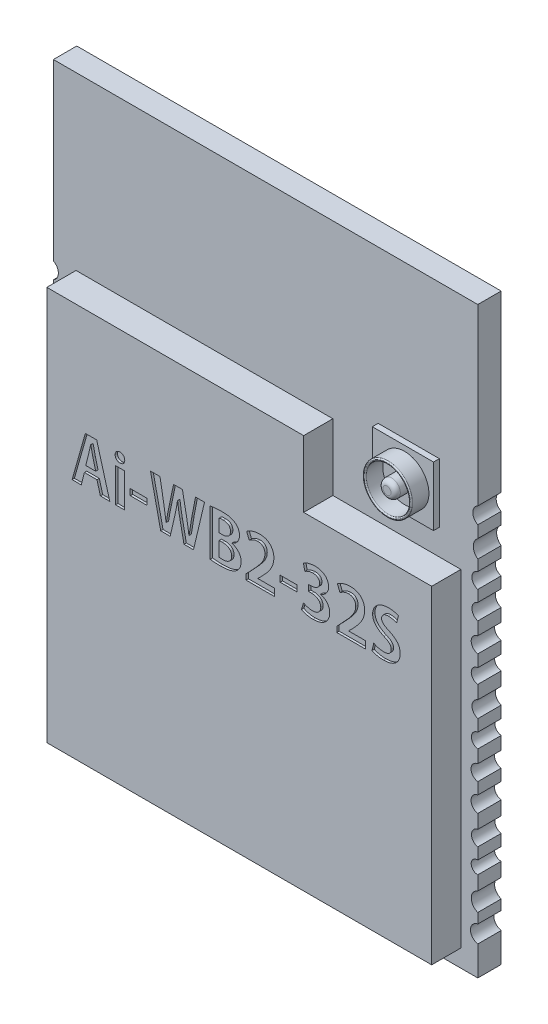
from build123d import *

# Parameters (mm, degrees)
BOSS_EXTRU_1_DEPTH      = 1
BOSS_EXTRU_2_DEPTH      = 1.25
COAXCADRE_W             = 2.617926319
COAXCADRE_H             = 2.543658905
BOSS_EXTRU_3_DEPTH      = 0.25
COAD_REFLIEF_R          = 1.042475493
COAD_REFLIEF_R_2        = 0.933619224
COAD_REFLIEF_R_3        = 0.369372033
BOSS_EXTRU_5_DEPTH      = 1
CONG_1_R                = 0.05
CONG_2_R                = 0.2
ESQUISSE7_W             = 0.383107528
ESQUISSE7_H             = 1.451751746
ESQUISSE7_W_2           = 0.716440922
ESQUISSE7_H_2           = 0.262443856
ENL_V_MAT_EXTRU_1_DEPTH = 0.1


with BuildPart() as part:
    # fond pcb → Boss.-Extru.1 (new body)
    with BuildSketch(Plane.XY):
        with BuildLine():
            Line((-9.810904604, 5.528505039), (-9.810904604, 5.018441254))
            ThreePointArc((-9.810904604, 5.018441254), (-9.618337887, 4.638599071), (-9.810904604, 4.258756888))
            Line((-9.810904604, 4.258756888), (-9.810904604, 3.797103699))
            ThreePointArc((-9.810904604, 3.797103699), (-9.557628015, 3.466729738), (-9.810904604, 3.136355778))
            Line((-9.810904604, 3.136355778), (-9.810904604, 2.653255527))
            ThreePointArc((-9.810904604, 2.653255527), (-9.560806021, 2.310466155), (-9.810904604, 1.967676782))
            Line((-9.810904604, 1.967676782), (-9.810904604, 1.414727565))
            ThreePointArc((-9.810904604, 1.414727565), (-9.528239409, 1.080368734), (-9.810904604, 0.746009903))
            Line((-9.810904604, 0.746009903), (-9.810904604, 0.232064282))
            ThreePointArc((-9.810904604, 0.232064282), (-9.530829797, -0.076435621), (-9.810904604, -0.384935524))
            Line((-9.810904604, -0.384935524), (-9.810904604, -0.956391193))
            ThreePointArc((-9.810904604, -0.956391193), (-9.563771815, -1.305723123), (-9.810904604, -1.655055053))
            Line((-9.810904604, -1.655055053), (-9.810904604, -2.155701883))
            ThreePointArc((-9.810904604, -2.155701883), (-9.536682912, -2.467131159), (-9.810904604, -2.778560434))
            Line((-9.810904604, -2.778560434), (-9.810904604, -3.327592238))
            ThreePointArc((-9.810904604, -3.327592238), (-9.522985317, -3.658586754), (-9.810904604, -3.98958127))
            Line((-9.810904604, -3.98958127), (-9.810904604, -4.48532252))
            ThreePointArc((-9.810904604, -4.48532252), (-9.521659552, -4.826224315), (-9.810904604, -5.16712611))
            Line((-9.810904604, -5.16712611), (-9.810904604, -5.758860272))
            ThreePointArc((-9.810904604, -5.758860272), (-9.540059049, -6.083008578), (-9.810904604, -6.407156885))
            Line((-9.810904604, -6.407156885), (-9.810904604, -6.895156212))
            ThreePointArc((-9.810904604, -6.895156212), (-9.528679561, -7.168746736), (-9.810904604, -7.442337261))
            Line((-9.810904604, -7.442337261), (-9.810904604, -8.04316978))
            ThreePointArc((-9.810904604, -8.04316978), (-9.530998458, -8.439992227), (-9.810904604, -8.836814674))
            Line((-9.810904604, -8.836814674), (-9.810904604, -9.267226472))
            ThreePointArc((-9.810904604, -9.267226472), (-9.498258669, -9.63677022), (-9.810904604, -10.006313969))
            Line((-9.810904604, -10.006313969), (-9.810904604, -11.267608596))
            Line((-9.810904604, -11.267608596), (-7.355200704, -11.267608596))
            ThreePointArc((-7.355200704, -11.267608596), (-6.993089856, -10.991870647), (-6.630979007, -11.267608596))
            Line((-6.630979007, -11.267608596), (-5.955813326, -11.267608596))
            ThreePointArc((-5.955813326, -11.267608596), (-5.54916478, -10.996984361), (-5.142516233, -11.267608596))
            Line((-5.142516233, -11.267608596), (-4.512187405, -11.267608596))
            ThreePointArc((-4.512187405, -11.267608596), (-4.118037923, -11.010624916), (-3.72388844, -11.267608596))
            Line((-3.72388844, -11.267608596), (-3.099198695, -11.267608596))
            ThreePointArc((-3.099198695, -11.267608596), (-2.710391479, -11.014580554), (-2.3158242, -11.258529123))
            Line((-2.3158242, -11.258529123), (-2.31298932, -11.269461703))
            Line((-2.31298932, -11.269461703), (-1.718131206, -11.267608596))
            ThreePointArc((-1.718131206, -11.267608596), (-1.323373729, -11.005956445), (-0.928616251, -11.267608596))
            Line((-0.928616251, -11.267608596), (-0.271146304, -11.267608596))
            ThreePointArc((-0.271146304, -11.267608596), (0.118853565, -11.015281805), (0.508853434, -11.267608596))
            Line((0.508853434, -11.267608596), (1.176730958, -11.267608596))
            ThreePointArc((1.176730958, -11.267608596), (1.536226215, -11.0110728), (1.895721472, -11.267608596))
            Line((1.895721472, -11.267608596), (2.565065894, -11.267608596))
            ThreePointArc((2.565065894, -11.267608596), (2.962688938, -11.005264515), (3.360311981, -11.267608596))
            Line((3.360311981, -11.267608596), (4.018275915, -11.267608596))
            ThreePointArc((4.018275915, -11.267608596), (4.37585402, -11.012835576), (4.733432125, -11.267608596))
            Line((4.733432125, -11.267608596), (5.473522243, -11.263142705))
            ThreePointArc((5.473522243, -11.263142705), (5.785246092, -11.007420546), (6.093252196, -11.267608596))
            Line((6.093252196, -11.267608596), (8.350588499, -11.267608596))
            Line((8.350588499, -11.267608596), (8.350588499, -10.006313969))
            ThreePointArc((8.350588499, -10.006313969), (8.037942564, -9.63677022), (8.350588499, -9.267226472))
            Line((8.350588499, -9.267226472), (8.350588499, -8.836814674))
            ThreePointArc((8.350588499, -8.836814674), (8.070682352, -8.439992227), (8.350588499, -8.04316978))
            Line((8.350588499, -8.04316978), (8.350588499, -7.442337261))
            ThreePointArc((8.350588499, -7.442337261), (8.068363456, -7.168746736), (8.350588499, -6.895156212))
            Line((8.350588499, -6.895156212), (8.350588499, -6.407156885))
            ThreePointArc((8.350588499, -6.407156885), (8.079742943, -6.083008578), (8.350588499, -5.758860272))
            Line((8.350588499, -5.758860272), (8.350588499, -5.16712611))
            ThreePointArc((8.350588499, -5.16712611), (8.061343447, -4.826224315), (8.350588499, -4.48532252))
            Line((8.350588499, -4.48532252), (8.350588499, -3.98958127))
            ThreePointArc((8.350588499, -3.98958127), (8.062669211, -3.658586754), (8.350588499, -3.327592238))
            Line((8.350588499, -3.327592238), (8.350588499, -2.778560434))
            ThreePointArc((8.350588499, -2.778560434), (8.076366807, -2.467131159), (8.350588499, -2.155701883))
            Line((8.350588499, -2.155701883), (8.350588499, -1.655055053))
            ThreePointArc((8.350588499, -1.655055053), (8.10345571, -1.305723123), (8.350588499, -0.956391193))
            Line((8.350588499, -0.956391193), (8.350588499, -0.384935524))
            ThreePointArc((8.350588499, -0.384935524), (8.070513692, -0.076435621), (8.350588499, 0.232064282))
            Line((8.350588499, 0.232064282), (8.350588499, 0.746009903))
            ThreePointArc((8.350588499, 0.746009903), (8.067923304, 1.080368734), (8.350588499, 1.414727565))
            Line((8.350588499, 1.414727565), (8.350588499, 1.967676782))
            ThreePointArc((8.350588499, 1.967676782), (8.100489916, 2.310466155), (8.350588499, 2.653255527))
            Line((8.350588499, 2.653255527), (8.350588499, 3.136355778))
            ThreePointArc((8.350588499, 3.136355778), (8.09731191, 3.466729738), (8.350588499, 3.797103699))
            Line((8.350588499, 3.797103699), (8.350588499, 4.258756888))
            ThreePointArc((8.350588499, 4.258756888), (8.158021781, 4.638599071), (8.350588499, 5.018441254))
            Line((8.350588499, 5.018441254), (8.350588499, 5.528505039))
            ThreePointArc((8.350588499, 5.528505039), (8.13837513, 5.879127896), (8.350588499, 6.229750754))
            Line((8.350588499, 6.229750754), (8.350588499, 13.692890171))
            Line((8.350588499, 13.692890171), (-9.810904604, 13.692890171))
            Line((-9.810904604, 13.692890171), (-9.810904604, 6.229750754))
            ThreePointArc((-9.810904604, 6.229750754), (-9.598691236, 5.879127896), (-9.810904604, 5.528505039))
        make_face()
    extrude(amount=-BOSS_EXTRU_1_DEPTH)

    # shield alu → Boss.-Extru.2 (add)
    with BuildSketch(Plane.XY):
        Polygon((-8.84180437, 6.358286248), (2.148090098, 6.358286248), (2.148090098, 3.513413278), (7.627000757, 3.513413278), (7.627000757, -10.517900776), (-8.84180437, -10.517900776), align=None)
    extrude(amount=BOSS_EXTRU_2_DEPTH)

    # coaxcadre → Boss.-Extru.3 (add)
    with BuildSketch(Plane.XY):
        with Locations((5.395145389, 5.88540961)):
            Rectangle(COAXCADRE_W, COAXCADRE_H)
    extrude(amount=BOSS_EXTRU_3_DEPTH)

    # coad reflief → Boss.-Extru.5 (add)
    with BuildSketch(Plane.XY):
        with Locations((5.466318326, 5.891598561)):
            Circle(COAD_REFLIEF_R)
        with Locations((5.466318326, 5.891598561)):
            Circle(COAD_REFLIEF_R_2, mode=Mode.SUBTRACT)
        with Locations((5.466318326, 5.854464855)):
            Circle(COAD_REFLIEF_R_3)
    extrude(amount=BOSS_EXTRU_5_DEPTH)

    # Congé1
    cong_1_edges = [part.edges().sort_by_distance(p)[0] for p in [
        (4.532699103, 5.891598561, 1),
        (4.423842833, 5.891598561, 1),
    ]]
    fillet(cong_1_edges, radius=CONG_1_R)

    # Congé2
    cong_2_edges = [part.edges().sort_by_distance(p)[0] for p in [
        (5.096946294, 5.854464855, 1),
    ]]
    fillet(cong_2_edges, radius=CONG_2_R)

    # Esquisse7 → Enlèv. mat.-Extru.1 (cut)
    with BuildSketch(Plane.XY.offset(1.25)):
        Polygon((-7.19342477, 1.770074266), (-7.761614861, -0.228100386), (-7.370658377, -0.228100386), (-7.232520419, 0.300994056), (-6.695606847, 0.300994056), (-6.552256136, -0.228100386), (-6.148267768, -0.228100386), (-6.70863873, 1.770074266), align=None)
        with BuildLine():
            add(Edge.make_bspline(
                [(-7.057893189, 1.049727829), (-7.050373964, 1.081676066), (-7.034602693, 1.148686205), (-7.012461293, 1.251786298), (-6.990337461, 1.356210723), (-6.976379811, 1.425543445), (-6.969646832, 1.458988604)],
                knots=[0, 0, 0, 0, 9.8461e-05, 0.000206518, 0.00031634, 0.000418688, 0.000418688, 0.000418688, 0.000418688], degree=3))
            Line((-6.969646832, 1.458988604), (-6.961457256, 1.459364942))
            add(Edge.make_bspline(
                [(-6.961457256, 1.459364942), (-6.954502063, 1.426435492), (-6.9400326, 1.357929632), (-6.918166943, 1.25374074), (-6.895002191, 1.149107394), (-6.878489745, 1.080258577), (-6.870476376, 1.046846749)],
                knots=[0, 0, 0, 0, 0.000100968, 0.000210052, 0.000319376, 0.000422452, 0.000422452, 0.000422452, 0.000422452], degree=3))
            Line((-6.870476376, 1.046846749), (-6.750340755, 0.587570646))
            Line((-6.750340755, 0.587570646), (-7.177786511, 0.587570646))
            Line((-7.177786511, 0.587570646), (-7.057893189, 1.049727829))
        make_face(mode=Mode.SUBTRACT)
        with BuildLine():
            add(Edge.make_bspline(
                [(-5.507519659, 1.614705059), (-5.508499645, 1.629100853), (-5.510392191, 1.656901967), (-5.520902405, 1.696552351), (-5.538985629, 1.731629997), (-5.563866341, 1.761584282), (-5.594148666, 1.786480237), (-5.630101476, 1.804362004), (-5.670856455, 1.815533443), (-5.699712228, 1.817130857), (-5.71474464, 1.817963029)],
                knots=[0, 0, 0, 0, 4.3222e-05, 8.347e-05, 0.00012209, 0.000160666, 0.000199534, 0.000238826, 0.000280265, 0.000325328, 0.000325328, 0.000325328, 0.000325328], degree=3))
            add(Edge.make_bspline(
                [(-5.71474464, 1.817963029), (-5.729277905, 1.817129964), (-5.757272576, 1.815525274), (-5.796980117, 1.804218639), (-5.832387198, 1.78637651), (-5.862631561, 1.761605013), (-5.887447873, 1.731534068), (-5.905921872, 1.696601634), (-5.917014819, 1.656850163), (-5.918647969, 1.628869221), (-5.919495809, 1.614343082)],
                knots=[0, 0, 0, 0, 4.3561e-05, 8.391e-05, 0.000122866, 0.000161734, 0.00020031, 0.000239104, 0.000279453, 0.000323014, 0.000323014, 0.000323014, 0.000323014], degree=3))
            add(Edge.make_bspline(
                [(-5.919495809, 1.614343082), (-5.918649687, 1.600186032), (-5.917006285, 1.572689164), (-5.905692439, 1.533686776), (-5.888212595, 1.4985451), (-5.863761408, 1.468123639), (-5.833525289, 1.443133558), (-5.798113359, 1.424662732), (-5.757859222, 1.413632315), (-5.729520108, 1.411720118), (-5.71474464, 1.410723135)],
                knots=[0, 0, 0, 0, 4.2435e-05, 8.2421e-05, 0.00012087, 0.000159501, 0.000198608, 0.000237737, 0.000278448, 0.000322797, 0.000322797, 0.000322797, 0.000322797], degree=3))
            add(Edge.make_bspline(
                [(-5.71474464, 1.410723135), (-5.700224915, 1.411452262), (-5.672157858, 1.412861686), (-5.632220948, 1.423564457), (-5.596823214, 1.441443412), (-5.565516908, 1.464989874), (-5.540643604, 1.49531375), (-5.521407964, 1.530280527), (-5.510703702, 1.570889518), (-5.508749622, 1.59945361), (-5.507519659, 1.614705059)],
                knots=[0, 0, 0, 0, 4.3527e-05, 8.4139e-05, 0.000122925, 0.000161917, 0.000200733, 0.000239705, 0.000280781, 0.000325505, 0.000325505, 0.000325505, 0.000325505], degree=3))
        make_face()
        with Locations((-5.712105306, 0.494958111)):
            Rectangle(ESQUISSE7_W, ESQUISSE7_H)
        with Locations((-4.915725069, 0.552879656)):
            Rectangle(ESQUISSE7_W_2, ESQUISSE7_H_2)
        with BuildLine():
            add(Edge.make_bspline(
                [(-2.64360157, 0.914449595), (-2.653942815, 0.854396642), (-2.674400927, 0.73559373), (-2.703544863, 0.558404536), (-2.731194217, 0.382518212), (-2.747359188, 0.265199728), (-2.755468077, 0.206348856)],
                knots=[0, 0, 0, 0, 0.00018281, 0.000361653, 0.000538709, 0.000716926, 0.000716926, 0.000716926, 0.000716926], degree=3))
            Line((-2.755468077, 0.206348856), (-2.76291897, 0.206659648))
            add(Edge.make_bspline(
                [(-2.76291897, 0.206659648), (-2.769900874, 0.26467159), (-2.783780189, 0.379993443), (-2.810605894, 0.552086445), (-2.839544405, 0.724318286), (-2.861114325, 0.839237686), (-2.871983935, 0.89714838)],
                knots=[0, 0, 0, 0, 0.000175279, 0.000348436, 0.000522444, 0.000699205, 0.000699205, 0.000699205, 0.000699205], degree=3))
            Line((-2.871983935, 0.89714838), (-3.040461619, 1.76787921))
            Line((-3.040461619, 1.76787921), (-3.419164672, 1.76787921))
            Line((-3.419164672, 1.76787921), (-3.600734629, 0.907774943))
            add(Edge.make_bspline(
                [(-3.600734629, 0.907774943), (-3.614164951, 0.846478633), (-3.640606658, 0.725798051), (-3.67425059, 0.546549043), (-3.705622498, 0.372638991), (-3.72234603, 0.257932868), (-3.730581379, 0.201446895)],
                knots=[0, 0, 0, 0, 0.000188239, 0.000370607, 0.000547101, 0.000718337, 0.000718337, 0.000718337, 0.000718337], degree=3))
            Line((-3.730581379, 0.201446895), (-3.738209025, 0.201446895))
            add(Edge.make_bspline(
                [(-3.738209025, 0.201446895), (-3.745839855, 0.256770439), (-3.761512784, 0.370399246), (-3.788061293, 0.543795791), (-3.816125562, 0.722256182), (-3.83700353, 0.842248505), (-3.847474311, 0.902427416)],
                knots=[0, 0, 0, 0, 0.00016754, 0.000344109, 0.000526242, 0.000709488, 0.000709488, 0.000709488, 0.000709488], degree=3))
            Line((-3.847474311, 0.902427416), (-4.000188535, 1.76787921))
            Line((-4.000188535, 1.76787921), (-4.407429534, 1.76787921))
            Line((-4.407429534, 1.76787921), (-3.969062257, -0.229925734))
            Line((-3.969062257, -0.229925734), (-3.564420638, -0.229925734))
            Line((-3.564420638, -0.229925734), (-3.369881398, 0.613254392))
            add(Edge.make_bspline(
                [(-3.369881398, 0.613254392), (-3.358156298, 0.665477773), (-3.334783014, 0.769581956), (-3.303784691, 0.927249011), (-3.275720616, 1.087828318), (-3.259046202, 1.196388297), (-3.250566207, 1.251597918)],
                knots=[0, 0, 0, 0, 0.000160564, 0.000320076, 0.000482, 0.000649568, 0.000649568, 0.000649568, 0.000649568], degree=3))
            Line((-3.250566207, 1.251597918), (-3.245376285, 1.25181665))
            add(Edge.make_bspline(
                [(-3.245376285, 1.25181665), (-3.238791014, 1.19628418), (-3.225865186, 1.08728288), (-3.202737067, 0.926236936), (-3.176022283, 0.768773062), (-3.154828594, 0.665066788), (-3.144231346, 0.613211676)],
                knots=[0, 0, 0, 0, 0.00016776, 0.000329285, 0.000488044, 0.000646816, 0.000646816, 0.000646816, 0.000646816], degree=3))
            Line((-3.144231346, 0.613211676), (-2.973021349, -0.229925734))
            Line((-2.973021349, -0.229925734), (-2.565785874, -0.229925734))
            Line((-2.565785874, -0.229925734), (-2.093703986, 1.76787921))
            Line((-2.093703986, 1.76787921), (-2.480188609, 1.76787921))
            Line((-2.480188609, 1.76787921), (-2.64360157, 0.914449595))
        make_face()
        with BuildLine():
            add(Edge.make_bspline(
                [(-1.849359681, -0.228241421), (-1.836926383, -0.23013493), (-1.810481642, -0.234162289), (-1.768346343, -0.238928889), (-1.721699368, -0.243049202), (-1.670517825, -0.246307617), (-1.614968175, -0.249400071), (-1.554752096, -0.2516264), (-1.490137601, -0.253023112), (-1.445513478, -0.253706308), (-1.422511572, -0.254058468)],
                knots=[0, 0, 0, 0, 3.7727e-05, 8.0243e-05, 0.000127184, 0.000178202, 0.00023409, 0.000294088, 0.000358962, 0.000427976, 0.000427976, 0.000427976, 0.000427976], degree=3))
            add(Edge.make_bspline(
                [(-1.422511572, -0.254058468), (-1.400890962, -0.253917225), (-1.358642953, -0.253641226), (-1.296649829, -0.251383895), (-1.237578643, -0.247481333), (-1.181305271, -0.24294806), (-1.128055272, -0.235825288), (-1.07739203, -0.228278797), (-1.02967141, -0.21827668), (-0.970745973, -0.204158776), (-0.903090641, -0.182599101), (-0.829327711, -0.150944025), (-0.764134561, -0.114180089), (-0.727292405, -0.083421829), (-0.709464684, -0.068538072)],
                knots=[0, 0, 0, 0, 6.4861e-05, 0.000126743, 0.000186063, 0.000242461, 0.00029606, 0.000347204, 0.000396086, 0.000442271, 0.000528966, 0.000608681, 0.000682861, 0.000752412, 0.000752412, 0.000752412, 0.000752412], degree=3))
            add(Edge.make_bspline(
                [(-0.709464684, -0.068538072), (-0.695173122, -0.05516164), (-0.666907077, -0.028705551), (-0.630591624, 0.01655376), (-0.599239245, 0.064803371), (-0.573103721, 0.11621769), (-0.55282825, 0.170145552), (-0.538178097, 0.225734967), (-0.528611727, 0.282818118), (-0.527515088, 0.321443934), (-0.526960879, 0.340964266)],
                knots=[0, 0, 0, 0, 5.8661e-05, 0.000116021, 0.000173546, 0.00023105, 0.000288689, 0.000346036, 0.000403317, 0.000461841, 0.000461841, 0.000461841, 0.000461841], degree=3))
            add(Edge.make_bspline(
                [(-0.526960879, 0.340964266), (-0.527621544, 0.356690671), (-0.528915148, 0.387483478), (-0.534527182, 0.432533688), (-0.543707269, 0.475356931), (-0.555679767, 0.516300818), (-0.571117875, 0.555229274), (-0.590139957, 0.592058531), (-0.612394385, 0.626750172), (-0.637753068, 0.659212421), (-0.665734699, 0.689370989), (-0.695842818, 0.717257327), (-0.727991309, 0.742610241), (-0.762047148, 0.765279081), (-0.798048558, 0.785460426), (-0.836281809, 0.802587519), (-0.876220817, 0.817952802), (-0.903963533, 0.82572403), (-0.917986592, 0.829652138)],
                knots=[0, 0, 0, 0, 4.7208e-05, 9.2435e-05, 0.000135995, 0.000178469, 0.000220271, 0.000261421, 0.000302632, 0.00034374, 0.000384833, 0.000425925, 0.000466736, 0.000507523, 0.000548543, 0.000590391, 0.000633112, 0.000676778, 0.000676778, 0.000676778, 0.000676778], degree=3))
            Line((-0.917986592, 0.829652138), (-0.917658125, 0.840220152))
            add(Edge.make_bspline(
                [(-0.917658125, 0.840220152), (-0.904736482, 0.845562119), (-0.879289618, 0.856082166), (-0.843164592, 0.874801451), (-0.809047996, 0.894569537), (-0.777770218, 0.916546359), (-0.74883516, 0.940034389), (-0.722505041, 0.965273732), (-0.698477778, 0.992123055), (-0.670764576, 1.030204857), (-0.641199214, 1.080304654), (-0.616348783, 1.144780695), (-0.600431528, 1.212365046), (-0.598718778, 1.258672923), (-0.597850787, 1.28214091)],
                knots=[0, 0, 0, 0, 4.1928e-05, 8.257e-05, 0.000121954, 0.000160135, 0.000197119, 0.000233657, 0.000269449, 0.000305046, 0.000374829, 0.000443242, 0.000511667, 0.000581974, 0.000581974, 0.000581974, 0.000581974], degree=3))
            add(Edge.make_bspline(
                [(-0.597850787, 1.28214091), (-0.598443978, 1.302804977), (-0.599601837, 1.343139483), (-0.610356669, 1.401649137), (-0.626159728, 1.456670964), (-0.649219941, 1.507536597), (-0.677415391, 1.554514378), (-0.711199543, 1.596763037), (-0.749484078, 1.634820374), (-0.778544209, 1.655811097), (-0.793175106, 1.666379291)],
                knots=[0, 0, 0, 0, 6.1933e-05, 0.000120888, 0.000177918, 0.000233279, 0.000287924, 0.000341867, 0.000395196, 0.00044927, 0.00044927, 0.00044927, 0.00044927], degree=3))
            add(Edge.make_bspline(
                [(-0.793175106, 1.666379291), (-0.81068216, 1.677685148), (-0.846052978, 1.700527223), (-0.903638646, 1.7282565), (-0.965080099, 1.750537278), (-1.030657085, 1.767472447), (-1.100924752, 1.77974292), (-1.176491534, 1.788125271), (-1.257646035, 1.793704009), (-1.313652913, 1.793787292), (-1.342571889, 1.793830295)],
                knots=[0, 0, 0, 0, 6.2474e-05, 0.00012622, 0.000191232, 0.000258271, 0.000329131, 0.000405043, 0.000486285, 0.00057302, 0.00057302, 0.00057302, 0.00057302], degree=3))
            add(Edge.make_bspline(
                [(-1.342571889, 1.793830295), (-1.390847854, 1.793225142), (-1.485343056, 1.792040618), (-1.601289213, 1.784931415), (-1.688390804, 1.77600413), (-1.747294702, 1.769523447), (-1.800490455, 1.761664846), (-1.833916941, 1.755343705), (-1.849736387, 1.752352158)],
                knots=[0, 0, 0, 0, 0.000144828, 0.000283485, 0.000348283, 0.000407497, 0.000461251, 0.000509547, 0.000509547, 0.000509547, 0.000509547], degree=3))
            Line((-1.849736387, 1.752352158), (-1.849359681, -0.228241421))
        make_face()
        with BuildLine():
            add(Edge.make_bspline(
                [(-1.466252153, 1.494249072), (-1.456849694, 1.496217877), (-1.435186319, 1.500754028), (-1.397704641, 1.504467998), (-1.351142322, 1.506446198), (-1.317059452, 1.506968796), (-1.298454234, 1.507254073)],
                knots=[0, 0, 0, 0, 2.8803e-05, 6.6364e-05, 0.000112799, 0.000168617, 0.000168617, 0.000168617, 0.000168617], degree=3))
            add(Edge.make_bspline(
                [(-1.298454234, 1.507254073), (-1.277281581, 1.50703822), (-1.236376661, 1.5066212), (-1.177599238, 1.495161128), (-1.123543973, 1.476888908), (-1.082885398, 1.454384136), (-1.053616718, 1.432502795), (-1.035100431, 1.412492916), (-1.019123299, 1.390066476), (-1.005798944, 1.364842896), (-0.99530456, 1.336693351), (-0.987412808, 1.305736494), (-0.982584455, 1.271975965), (-0.981512105, 1.248596676), (-0.980957946, 1.236514959)],
                knots=[0, 0, 0, 0, 6.3403e-05, 0.000122493, 0.00017878, 0.000233973, 0.000261125, 0.000288067, 0.000315375, 0.000343545, 0.000373379, 0.000405297, 0.000439213, 0.000475483, 0.000475483, 0.000475483, 0.000475483], degree=3))
            add(Edge.make_bspline(
                [(-0.980957946, 1.236514959), (-0.981247947, 1.226068354), (-0.981820267, 1.205451889), (-0.986326134, 1.175322052), (-0.994117491, 1.14690912), (-1.003739588, 1.119812011), (-1.016725778, 1.094396431), (-1.032546398, 1.070601181), (-1.051416609, 1.048621571), (-1.072281792, 1.027773505), (-1.096228325, 1.009396768), (-1.122270576, 0.993022948), (-1.150833399, 0.979515847), (-1.181499747, 0.968183746), (-1.21455591, 0.959141114), (-1.249845907, 0.952399433), (-1.287552158, 0.948264134), (-1.313401309, 0.947378811), (-1.326734782, 0.946922145)],
                knots=[0, 0, 0, 0, 3.1333e-05, 6.1837e-05, 9.1106e-05, 0.000119617, 0.000147947, 0.000176498, 0.000205128, 0.000234726, 0.000264821, 0.000295478, 0.000326847, 0.000359418, 0.000393449, 0.000429538, 0.000467098, 0.000507112, 0.000507112, 0.000507112, 0.000507112], degree=3))
            Line((-1.326734782, 0.946922145), (-1.466252153, 0.947298851))
            Line((-1.466252153, 0.947298851), (-1.466252153, 1.494249072))
        make_face(mode=Mode.SUBTRACT)
        with BuildLine():
            add(Edge.make_bspline(
                [(-1.324143872, 0.665247517), (-1.299312962, 0.664656859), (-1.250695334, 0.663500383), (-1.179989853, 0.650512574), (-1.113941298, 0.628028026), (-1.062943509, 0.601807553), (-1.02593099, 0.575878144), (-1.001368656, 0.553147283), (-0.981186102, 0.526660728), (-0.963327775, 0.497872449), (-0.950013521, 0.465433496), (-0.939647924, 0.430083446), (-0.933506884, 0.391554101), (-0.931723693, 0.36486424), (-0.930807107, 0.351145263)],
                knots=[0, 0, 0, 0, 7.4428e-05, 0.000145726, 0.000214649, 0.000283124, 0.00031692, 0.000349999, 0.000383038, 0.000416536, 0.000451343, 0.000487859, 0.000526851, 0.000568092, 0.000568092, 0.000568092, 0.000568092], degree=3))
            add(Edge.make_bspline(
                [(-0.930807107, 0.351145263), (-0.931424362, 0.337673477), (-0.932624582, 0.311478296), (-0.938733208, 0.273562461), (-0.948088905, 0.238572524), (-0.960451694, 0.206201989), (-0.977021124, 0.1772974), (-0.995717765, 0.150308245), (-1.018652287, 0.126985348), (-1.044479076, 0.106511929), (-1.072753844, 0.089173911), (-1.102388426, 0.073472791), (-1.133576668, 0.060139745), (-1.166831608, 0.050231463), (-1.201256422, 0.041744379), (-1.237476844, 0.036264803), (-1.275126394, 0.032659871), (-1.300833441, 0.032565681), (-1.313914267, 0.032517753)],
                knots=[0, 0, 0, 0, 4.0433e-05, 7.862e-05, 0.000114933, 0.000148964, 0.000182219, 0.000214656, 0.00024719, 0.000279932, 0.000313307, 0.000346534, 0.0003805, 0.000414849, 0.000450518, 0.000486784, 0.000524644, 0.000563867, 0.000563867, 0.000563867, 0.000563867], degree=3))
            add(Edge.make_bspline(
                [(-1.313914267, 0.032517753), (-1.329253101, 0.032500288), (-1.358184661, 0.032467345), (-1.398909398, 0.034575163), (-1.434507414, 0.03698427), (-1.456218985, 0.040892645), (-1.466252153, 0.042698751)],
                knots=[0, 0, 0, 0, 4.6005e-05, 8.6772e-05, 0.000122345, 0.000152907, 0.000152907, 0.000152907, 0.000152907], degree=3))
            Line((-1.466252153, 0.042698751), (-1.466252153, 0.665247517))
            Line((-1.466252153, 0.665247517), (-1.324143872, 0.665247517))
        make_face(mode=Mode.SUBTRACT)
        with BuildLine():
            Line((0.18917588, 0.080783222), (0.18917588, 0.086026171))
            Line((0.18917588, 0.086026171), (0.353377604, 0.248557574))
            add(Edge.make_bspline(
                [(0.353377604, 0.248557574), (0.388866031, 0.284405971), (0.458699005, 0.354947279), (0.555204007, 0.465103788), (0.642337014, 0.576745294), (0.709018736, 0.670679491), (0.755882691, 0.747370653), (0.786224099, 0.805835127), (0.812225528, 0.865276029), (0.833864954, 0.925855147), (0.850881526, 0.987485627), (0.863319712, 1.050246719), (0.871362782, 1.114150615), (0.873281222, 1.15718195), (0.874246015, 1.17882264)],
                knots=[0, 0, 0, 0, 0.000151306, 0.000297735, 0.000439018, 0.000576051, 0.000643047, 0.000708484, 0.000773495, 0.000837541, 0.000901304, 0.000965123, 0.001029338, 0.001094304, 0.001094304, 0.001094304, 0.001094304], degree=3))
            add(Edge.make_bspline(
                [(0.874246015, 1.17882264), (0.873985629, 1.199079604), (0.873472999, 1.238960214), (0.866398387, 1.297477056), (0.855214139, 1.353669969), (0.839111246, 1.407297304), (0.817667363, 1.458167719), (0.792059783, 1.50659463), (0.761600055, 1.552543132), (0.726694658, 1.5958854), (0.686842138, 1.635846815), (0.641045051, 1.67015312), (0.590567597, 1.699902733), (0.534602207, 1.723919658), (0.473682487, 1.74307443), (0.407663564, 1.757249624), (0.336554272, 1.766877832), (0.287299656, 1.768737652), (0.261877878, 1.76969756)],
                knots=[0, 0, 0, 0, 6.0738e-05, 0.000119577, 0.000176519, 0.000232465, 0.000287228, 0.000341881, 0.000396578, 0.000452347, 0.000508607, 0.000565395, 0.000623534, 0.000683989, 0.000747671, 0.000814828, 0.000886342, 0.000962624, 0.000962624, 0.000962624, 0.000962624], degree=3))
            add(Edge.make_bspline(
                [(0.261877878, 1.76969756), (0.23381876, 1.768755735), (0.178652442, 1.766904036), (0.097771796, 1.756630546), (0.020439138, 1.740066535), (-0.052610717, 1.717319949), (-0.121021392, 1.690786746), (-0.183492696, 1.660905573), (-0.240434537, 1.629350615), (-0.274175231, 1.604515096), (-0.290535496, 1.592472792)],
                knots=[0, 0, 0, 0, 8.419e-05, 0.000165523, 0.000244215, 0.000321147, 0.000394811, 0.000464132, 0.000528816, 0.000589702, 0.000589702, 0.000589702, 0.000589702], degree=3))
            Line((-0.290535496, 1.592472792), (-0.183535969, 1.315497595))
            add(Edge.make_bspline(
                [(-0.183535969, 1.315497595), (-0.171659587, 1.324246543), (-0.147176062, 1.342282768), (-0.107755644, 1.367337475), (-0.064853652, 1.39105334), (-0.019502646, 1.413708532), (0.028507682, 1.433037175), (0.078617499, 1.447465227), (0.130575296, 1.456775481), (0.16593738, 1.458495627), (0.183823565, 1.459365678)],
                knots=[0, 0, 0, 0, 4.4244e-05, 9.1211e-05, 0.000139995, 0.00019126, 0.000243216, 0.000295011, 0.000347457, 0.000401134, 0.000401134, 0.000401134, 0.000401134], degree=3))
            add(Edge.make_bspline(
                [(0.183823565, 1.459365678), (0.196786075, 1.458820178), (0.221919785, 1.457762477), (0.258246282, 1.452796187), (0.291857719, 1.445401152), (0.322885077, 1.435175765), (0.351123951, 1.422043109), (0.37667477, 1.406182403), (0.399173891, 1.387333778), (0.425762628, 1.359313811), (0.452256361, 1.318600579), (0.475799414, 1.264786438), (0.48910877, 1.205103324), (0.490446648, 1.163679056), (0.491138856, 1.142246465)],
                knots=[0, 0, 0, 0, 3.8904e-05, 7.5434e-05, 0.00010983, 0.000142026, 0.000173234, 0.000203051, 0.000231971, 0.000261045, 0.000318669, 0.000376599, 0.000436517, 0.000500754, 0.000500754, 0.000500754, 0.000500754], degree=3))
            add(Edge.make_bspline(
                [(0.491138856, 1.142246465), (0.490447703, 1.125752458), (0.489053483, 1.092480106), (0.481118024, 1.042542708), (0.469186503, 0.991968587), (0.451440451, 0.941078316), (0.429587097, 0.889403821), (0.403083871, 0.83719524), (0.371551292, 0.784645849), (0.3350317, 0.731428416), (0.294148731, 0.676883861), (0.249397175, 0.620254959), (0.201242944, 0.560966904), (0.148717086, 0.499576115), (0.092285986, 0.435836054), (0.031268186, 0.370359795), (-0.033022022, 0.302048671), (-0.077672086, 0.256183257), (-0.100490213, 0.232744035)],
                knots=[0, 0, 0, 0, 4.9489e-05, 9.9831e-05, 0.000151413, 0.000205192, 0.000261289, 0.000319637, 0.000380684, 0.000445004, 0.00051318, 0.000585145, 0.000661527, 0.000742304, 0.00082751, 0.000916899, 0.001010791, 0.001108924, 0.001108924, 0.001108924, 0.001108924], degree=3))
            Line((-0.100490213, 0.232744035), (-0.31906755, -5.0538e-05))
            Line((-0.31906755, -5.0538e-05), (-0.31906755, -0.229925734))
            Line((-0.31906755, -0.229925734), (0.911111993, -0.229925734))
            Line((0.911111993, -0.229925734), (0.911111993, 0.080783222))
            Line((0.911111993, 0.080783222), (0.18917588, 0.080783222))
        make_face()
        with Locations((1.503582297, 0.552879656)):
            Rectangle(ESQUISSE7_W_2, ESQUISSE7_H_2)
        with BuildLine():
            add(Edge.make_bspline(
                [(2.202998366, 1.355582695), (2.21323899, 1.361798295), (2.234777274, 1.37487107), (2.270305274, 1.392176644), (2.30974361, 1.409667002), (2.352755384, 1.426458296), (2.398716704, 1.441234114), (2.446754799, 1.452197004), (2.496356127, 1.459057977), (2.529956948, 1.460514568), (2.546946172, 1.461251048)],
                knots=[0, 0, 0, 0, 3.5921e-05, 7.555e-05, 0.00011843, 0.000165347, 0.000214002, 0.000263123, 0.000312984, 0.000363978, 0.000363978, 0.000363978, 0.000363978], degree=3))
            add(Edge.make_bspline(
                [(2.546946172, 1.461251048), (2.558641843, 1.460883228), (2.581326852, 1.460169801), (2.614257223, 1.456912959), (2.644688487, 1.451124636), (2.673029131, 1.444085523), (2.699040662, 1.434824035), (2.722399961, 1.423005397), (2.743658292, 1.409684641), (2.768257897, 1.389392306), (2.794141069, 1.359839685), (2.816198396, 1.318685835), (2.830114113, 1.272591791), (2.83136552, 1.240137676), (2.832014098, 1.223317369)],
                knots=[0, 0, 0, 0, 3.51e-05, 6.8081e-05, 9.9143e-05, 0.000127952, 0.000155625, 0.000181763, 0.000206345, 0.000230727, 0.000277231, 0.000323124, 0.000369897, 0.000420219, 0.000420219, 0.000420219, 0.000420219], degree=3))
            add(Edge.make_bspline(
                [(2.832014098, 1.223317369), (2.831146572, 1.211970105), (2.829445703, 1.189722685), (2.82250546, 1.157751963), (2.812786724, 1.127910695), (2.799458821, 1.100517986), (2.782855139, 1.075505029), (2.76280395, 1.053104367), (2.740238205, 1.032407839), (2.705321476, 1.00937846), (2.658924534, 0.985545768), (2.600771885, 0.96456999), (2.540985979, 0.951548153), (2.500504324, 0.949973984), (2.480204079, 0.949184589)],
                knots=[0, 0, 0, 0, 3.4106e-05, 6.6868e-05, 9.7871e-05, 0.000128058, 0.000157968, 0.000187623, 0.000218061, 0.000249542, 0.000312785, 0.000374091, 0.000434585, 0.000495436, 0.000495436, 0.000495436, 0.000495436], degree=3))
            Line((2.480204079, 0.949184589), (2.355423893, 0.949561295))
            Line((2.355423893, 0.949561295), (2.355423893, 0.687117807))
            Line((2.355423893, 0.687117807), (2.488349097, 0.687117807))
            add(Edge.make_bspline(
                [(2.488349097, 0.687117807), (2.500972126, 0.68672657), (2.525958555, 0.685952141), (2.5630048, 0.682857013), (2.598857916, 0.676200472), (2.63351372, 0.667599356), (2.667085469, 0.65677578), (2.699044714, 0.642560786), (2.730099871, 0.62649661), (2.759463948, 0.607681929), (2.786694435, 0.586416373), (2.810622536, 0.562069572), (2.831111538, 0.535255892), (2.847951368, 0.505530397), (2.861517522, 0.473284976), (2.871077754, 0.438121793), (2.878235807, 0.40068779), (2.879585963, 0.374684629), (2.880279567, 0.36132626)],
                knots=[0, 0, 0, 0, 3.7888e-05, 7.4997e-05, 0.000111388, 0.000147146, 0.000182084, 0.00021704, 0.000251954, 0.00028689, 0.000321517, 0.00035538, 0.000389016, 0.000422457, 0.000457612, 0.000493661, 0.000531604, 0.000571687, 0.000571687, 0.000571687, 0.000571687], degree=3))
            add(Edge.make_bspline(
                [(2.880279567, 0.36132626), (2.880124921, 0.351130021), (2.879818096, 0.330900242), (2.875477607, 0.301234384), (2.868722133, 0.272522793), (2.85894137, 0.245093905), (2.846210408, 0.218825344), (2.831351825, 0.193405812), (2.812775636, 0.169673327), (2.792442505, 0.146626966), (2.768769469, 0.125754036), (2.742445074, 0.107219329), (2.713088253, 0.091756616), (2.681064165, 0.07897611), (2.646326532, 0.068248142), (2.60850685, 0.061010672), (2.568062793, 0.055989843), (2.540174464, 0.054932098), (2.52583003, 0.054388044)],
                knots=[0, 0, 0, 0, 3.0564e-05, 6.064e-05, 8.9724e-05, 0.000118944, 0.000147785, 0.000177208, 0.000207074, 0.000238044, 0.000269296, 0.000301515, 0.000334409, 0.00036858, 0.000404842, 0.000443296, 0.00048394, 0.000526985, 0.000526985, 0.000526985, 0.000526985], degree=3))
            add(Edge.make_bspline(
                [(2.52583003, 0.054388044), (2.506698317, 0.055068399), (2.468811436, 0.056415719), (2.412829269, 0.064123157), (2.358117597, 0.074186403), (2.305918437, 0.089150231), (2.257256482, 0.105786696), (2.213601218, 0.123450766), (2.175570817, 0.141186964), (2.153181887, 0.154759536), (2.14272287, 0.161099979)],
                knots=[0, 0, 0, 0, 5.7395e-05, 0.00011366, 0.000169345, 0.000224146, 0.000276376, 0.00032357, 0.000365396, 0.000402066, 0.000402066, 0.000402066, 0.000402066], degree=3))
            Line((2.14272287, 0.161099979), (2.057041279, -0.131411475))
            add(Edge.make_bspline(
                [(2.057041279, -0.131411475), (2.070602358, -0.139801391), (2.099342937, -0.1575825), (2.148206215, -0.178959458), (2.203205443, -0.199674637), (2.264528929, -0.217266739), (2.330924288, -0.232471595), (2.401504318, -0.243169963), (2.475667851, -0.250134131), (2.526316675, -0.251233607), (2.552225208, -0.251796024)],
                knots=[0, 0, 0, 0, 4.7786e-05, 0.000101275, 0.000159619, 0.000224053, 0.000292478, 0.000363834, 0.000438052, 0.000515774, 0.000515774, 0.000515774, 0.000515774], degree=3))
            add(Edge.make_bspline(
                [(2.552225208, -0.251796024), (2.58002634, -0.250782271), (2.634134281, -0.248809255), (2.712692727, -0.239814983), (2.786186704, -0.225498839), (2.854714574, -0.206327821), (2.918489137, -0.182296697), (2.977115772, -0.152824949), (3.030867501, -0.118365027), (3.078980957, -0.078648937), (3.121927403, -0.035331372), (3.159544332, 0.010841955), (3.191389792, 0.059755459), (3.217713805, 0.111234746), (3.237558152, 0.165660466), (3.2525125, 0.222406644), (3.261142402, 0.282006979), (3.262630064, 0.322586775), (3.263386727, 0.34322671)],
                knots=[0, 0, 0, 0, 8.3437e-05, 0.000162388, 0.000236931, 0.000307839, 0.000375628, 0.000441058, 0.000504337, 0.000566764, 0.000627823, 0.000687067, 0.000745113, 0.000802618, 0.000860124, 0.000918565, 0.000978398, 0.001040331, 0.001040331, 0.001040331, 0.001040331], degree=3))
            add(Edge.make_bspline(
                [(3.263386727, 0.34322671), (3.262768198, 0.359711464), (3.26156018, 0.391907056), (3.255385484, 0.438936494), (3.246027226, 0.483596304), (3.233217483, 0.52602105), (3.216956393, 0.565977256), (3.197713646, 0.603786571), (3.174622394, 0.63877308), (3.148420488, 0.671284666), (3.119969615, 0.701227274), (3.089607665, 0.728449599), (3.057933459, 0.75322029), (3.024118356, 0.774720593), (2.988661322, 0.793574659), (2.951581713, 0.809750275), (2.91300056, 0.823670525), (2.886258185, 0.830148048), (2.872738088, 0.833422878)],
                knots=[0, 0, 0, 0, 4.9467e-05, 9.6612e-05, 0.000142094, 0.00018623, 0.000229363, 0.000271356, 0.000313294, 0.00035487, 0.000396478, 0.000437062, 0.000477112, 0.000516964, 0.000557111, 0.000597465, 0.000638252, 0.000679958, 0.000679958, 0.000679958, 0.000679958], degree=3))
            Line((2.872738088, 0.833422878), (2.872837143, 0.838529211))
            add(Edge.make_bspline(
                [(2.872837143, 0.838529211), (2.886457973, 0.843545175), (2.913223119, 0.853401623), (2.951311814, 0.871253503), (2.986947765, 0.89092874), (3.020098114, 0.912343774), (3.050731087, 0.935529618), (3.079366928, 0.959934395), (3.104841006, 0.986821275), (3.127989614, 1.015132528), (3.148310049, 1.044971781), (3.166126884, 1.075967954), (3.181225283, 1.108136637), (3.193818406, 1.141359181), (3.203157853, 1.175872349), (3.209939074, 1.211417302), (3.214199329, 1.248101931), (3.214811411, 1.272954022), (3.215121258, 1.285534575)],
                knots=[0, 0, 0, 0, 4.3529e-05, 8.5535e-05, 0.000126042, 0.000165577, 0.000203813, 0.000241236, 0.000278307, 0.00031476, 0.000350843, 0.000386482, 0.000421905, 0.000457344, 0.000492929, 0.000529018, 0.000565829, 0.000603566, 0.000603566, 0.000603566, 0.000603566], degree=3))
            add(Edge.make_bspline(
                [(3.215121258, 1.285534575), (3.214695691, 1.30189857), (3.213853909, 1.334267039), (3.206897542, 1.381769863), (3.195710148, 1.427321627), (3.179470892, 1.470612318), (3.159769367, 1.512392819), (3.13443075, 1.551622116), (3.105283323, 1.589213582), (3.071773678, 1.624684026), (3.033761425, 1.657158807), (2.991197247, 1.685538528), (2.944421646, 1.709808872), (2.893207004, 1.729797837), (2.837684706, 1.745311914), (2.77813983, 1.757601632), (2.714166962, 1.765024323), (2.670016756, 1.766614856), (2.64724785, 1.767435117)],
                knots=[0, 0, 0, 0, 4.9072e-05, 9.7065e-05, 0.000143707, 0.000189518, 0.00023556, 0.000282006, 0.000329298, 0.00037811, 0.00042813, 0.000478957, 0.00053124, 0.000585927, 0.000643575, 0.000703993, 0.000768163, 0.000836498, 0.000836498, 0.000836498, 0.000836498], degree=3))
            add(Edge.make_bspline(
                [(2.64724785, 1.767435117), (2.620835139, 1.76662887), (2.5690274, 1.765047441), (2.492747286, 1.757165506), (2.419717025, 1.743889616), (2.350422388, 1.72644195), (2.286652357, 1.705097638), (2.228669514, 1.68350786), (2.178203793, 1.658943044), (2.148000695, 1.640457547), (2.133673095, 1.631688485)],
                knots=[0, 0, 0, 0, 7.9258e-05, 0.000155463, 0.000229796, 0.000301771, 0.00036962, 0.000431453, 0.000487273, 0.00053765, 0.00053765, 0.00053765, 0.00053765], degree=3))
            Line((2.133673095, 1.631688485), (2.202998366, 1.355582695))
        make_face()
        with BuildLine():
            Line((4.074546128, 0.080783222), (4.074546128, 0.086026171))
            Line((4.074546128, 0.086026171), (4.238747851, 0.248557574))
            add(Edge.make_bspline(
                [(4.238747851, 0.248557574), (4.274236279, 0.284405971), (4.344069252, 0.354947279), (4.440574255, 0.465103788), (4.527707262, 0.576745294), (4.594388984, 0.670679491), (4.641252938, 0.747370653), (4.671594347, 0.805835127), (4.697595776, 0.865276029), (4.719235202, 0.925855147), (4.736251774, 0.987485627), (4.74868996, 1.050246719), (4.75673303, 1.114150615), (4.758651469, 1.15718195), (4.759616263, 1.17882264)],
                knots=[0, 0, 0, 0, 0.000151306, 0.000297735, 0.000439018, 0.000576051, 0.000643047, 0.000708484, 0.000773495, 0.000837541, 0.000901304, 0.000965123, 0.001029338, 0.001094304, 0.001094304, 0.001094304, 0.001094304], degree=3))
            add(Edge.make_bspline(
                [(4.759616263, 1.17882264), (4.759355877, 1.199079604), (4.758843247, 1.238960214), (4.751768635, 1.297477056), (4.740584387, 1.353669969), (4.724481493, 1.407297304), (4.703037611, 1.458167719), (4.677430031, 1.50659463), (4.646970303, 1.552543132), (4.612064906, 1.5958854), (4.572212386, 1.635846815), (4.526415299, 1.67015312), (4.475937845, 1.699902733), (4.419972455, 1.723919658), (4.359052735, 1.74307443), (4.293033812, 1.757249624), (4.221924519, 1.766877832), (4.172669904, 1.768737652), (4.147248126, 1.76969756)],
                knots=[0, 0, 0, 0, 6.0738e-05, 0.000119577, 0.000176519, 0.000232465, 0.000287228, 0.000341881, 0.000396578, 0.000452347, 0.000508607, 0.000565395, 0.000623534, 0.000683989, 0.000747671, 0.000814828, 0.000886342, 0.000962624, 0.000962624, 0.000962624, 0.000962624], degree=3))
            add(Edge.make_bspline(
                [(4.147248126, 1.76969756), (4.119189007, 1.768755735), (4.06402269, 1.766904036), (3.983142044, 1.756630546), (3.905809386, 1.740066535), (3.832759531, 1.717319949), (3.764348856, 1.690786746), (3.701877552, 1.660905573), (3.64493571, 1.629350615), (3.611195017, 1.604515096), (3.594834751, 1.592472792)],
                knots=[0, 0, 0, 0, 8.419e-05, 0.000165523, 0.000244215, 0.000321147, 0.000394811, 0.000464132, 0.000528816, 0.000589702, 0.000589702, 0.000589702, 0.000589702], degree=3))
            Line((3.594834751, 1.592472792), (3.701834279, 1.315497595))
            add(Edge.make_bspline(
                [(3.701834279, 1.315497595), (3.713710661, 1.324246543), (3.738194185, 1.342282768), (3.777614604, 1.367337475), (3.820516596, 1.39105334), (3.865867601, 1.413708532), (3.91387793, 1.433037175), (3.963987746, 1.447465227), (4.015945544, 1.456775481), (4.051307628, 1.458495627), (4.069193813, 1.459365678)],
                knots=[0, 0, 0, 0, 4.4244e-05, 9.1211e-05, 0.000139995, 0.00019126, 0.000243216, 0.000295011, 0.000347457, 0.000401134, 0.000401134, 0.000401134, 0.000401134], degree=3))
            add(Edge.make_bspline(
                [(4.069193813, 1.459365678), (4.082156323, 1.458820178), (4.107290033, 1.457762477), (4.143616529, 1.452796187), (4.177227967, 1.445401152), (4.208255325, 1.435175765), (4.236494198, 1.422043109), (4.262045018, 1.406182403), (4.284544139, 1.387333778), (4.311132876, 1.359313811), (4.337626609, 1.318600579), (4.361169662, 1.264786438), (4.374479018, 1.205103324), (4.375816896, 1.163679056), (4.376509104, 1.142246465)],
                knots=[0, 0, 0, 0, 3.8904e-05, 7.5434e-05, 0.00010983, 0.000142026, 0.000173234, 0.000203051, 0.000231971, 0.000261045, 0.000318669, 0.000376599, 0.000436517, 0.000500754, 0.000500754, 0.000500754, 0.000500754], degree=3))
            add(Edge.make_bspline(
                [(4.376509104, 1.142246465), (4.375817951, 1.125752458), (4.374423731, 1.092480106), (4.366488272, 1.042542708), (4.354556751, 0.991968587), (4.336810699, 0.941078316), (4.314957345, 0.889403821), (4.288454118, 0.83719524), (4.25692154, 0.784645849), (4.220401948, 0.731428416), (4.179518979, 0.676883861), (4.134767423, 0.620254959), (4.086613192, 0.560966904), (4.034087334, 0.499576115), (3.977656234, 0.435836054), (3.916638434, 0.370359795), (3.852348226, 0.302048671), (3.807698161, 0.256183257), (3.784880035, 0.232744035)],
                knots=[0, 0, 0, 0, 4.9489e-05, 9.9831e-05, 0.000151413, 0.000205192, 0.000261289, 0.000319637, 0.000380684, 0.000445004, 0.00051318, 0.000585145, 0.000661527, 0.000742304, 0.00082751, 0.000916899, 0.001010791, 0.001108924, 0.001108924, 0.001108924, 0.001108924], degree=3))
            Line((3.784880035, 0.232744035), (3.566302698, -5.0538e-05))
            Line((3.566302698, -5.0538e-05), (3.566302698, -0.229925734))
            Line((3.566302698, -0.229925734), (4.796482241, -0.229925734))
            Line((4.796482241, -0.229925734), (4.796482241, 0.080783222))
            Line((4.796482241, 0.080783222), (4.074546128, 0.080783222))
        make_face()
        with BuildLine():
            add(Edge.make_bspline(
                [(5.074804077, -0.146307002), (5.088002425, -0.15360999), (5.116166438, -0.16919387), (5.164207103, -0.187650076), (5.218923583, -0.206036804), (5.280514774, -0.221618195), (5.346602508, -0.235630235), (5.415994597, -0.245717474), (5.487623807, -0.252269426), (5.536248773, -0.253456632), (5.560898462, -0.254058468)],
                knots=[0, 0, 0, 0, 4.5203e-05, 9.6459e-05, 0.000154052, 0.000218347, 0.000286901, 0.000356653, 0.000428583, 0.000502537, 0.000502537, 0.000502537, 0.000502537], degree=3))
            add(Edge.make_bspline(
                [(5.560898462, -0.254058468), (5.588954885, -0.253353236), (5.643568528, -0.251980455), (5.722759486, -0.242916934), (5.797141429, -0.230194551), (5.866269376, -0.211454073), (5.930783759, -0.188835805), (5.989957682, -0.160292117), (6.044226211, -0.127026485), (6.093375052, -0.089021382), (6.136600955, -0.046451577), (6.175283283, -0.0014008), (6.206818653, 0.047913167), (6.233742453, 0.099702461), (6.253840932, 0.155339106), (6.2692814, 0.213939251), (6.277710327, 0.27611872), (6.279212637, 0.318568615), (6.279978534, 0.340210118)],
                knots=[0, 0, 0, 0, 8.4156e-05, 0.000163815, 0.000238891, 0.000310326, 0.00037843, 0.000443699, 0.000507013, 0.000569088, 0.000629619, 0.000688762, 0.000746808, 0.00080482, 0.000863517, 0.000923879, 0.000986324, 0.001051269, 0.001051269, 0.001051269, 0.001051269], degree=3))
            add(Edge.make_bspline(
                [(6.279978534, 0.340210118), (6.279709247, 0.356433942), (6.279177741, 0.388455722), (6.274353813, 0.435670003), (6.265367168, 0.481063691), (6.254062362, 0.525189334), (6.237877154, 0.567220993), (6.219123993, 0.608025293), (6.196258754, 0.646852554), (6.17021264, 0.684437931), (6.140125205, 0.720340855), (6.106426384, 0.755196663), (6.068718881, 0.788702511), (6.026867668, 0.820672072), (5.98170239, 0.852178561), (5.932204509, 0.881796549), (5.878828564, 0.910077515), (5.841638144, 0.927709418), (5.822587801, 0.936741148)],
                knots=[0, 0, 0, 0, 4.8666e-05, 9.6054e-05, 0.000142127, 0.000187402, 0.000232507, 0.000277041, 0.000321989, 0.000367492, 0.000414081, 0.000462348, 0.000512827, 0.000565246, 0.000620264, 0.000677947, 0.000738168, 0.000801411, 0.000801411, 0.000801411, 0.000801411], degree=3))
            add(Edge.make_bspline(
                [(5.822587801, 0.936741148), (5.808106323, 0.943344755), (5.780019292, 0.956152545), (5.739739043, 0.97567126), (5.702668686, 0.994955407), (5.668720989, 1.013814343), (5.637606855, 1.032156285), (5.609908683, 1.050738589), (5.584861463, 1.068241178), (5.563027037, 1.085827195), (5.543822306, 1.103583643), (5.527480986, 1.122541554), (5.513749134, 1.142812633), (5.502487943, 1.164009389), (5.494026088, 1.186476498), (5.488134521, 1.209878628), (5.484015832, 1.234485564), (5.483989009, 1.251329183), (5.483975371, 1.259893545)],
                knots=[0, 0, 0, 0, 4.7747e-05, 9.2606e-05, 0.000134264, 0.000173086, 0.000209106, 0.000242572, 0.000273125, 0.000300744, 0.000326619, 0.000351486, 0.000375646, 0.000399934, 0.000423325, 0.000447469, 0.000472267, 0.00049792, 0.00049792, 0.00049792, 0.00049792], degree=3))
            add(Edge.make_bspline(
                [(5.483975371, 1.259893545), (5.484721591, 1.274196067), (5.486199473, 1.302522103), (5.499741052, 1.343535891), (5.522153862, 1.381497905), (5.547870783, 1.409753513), (5.572530662, 1.430247066), (5.594197038, 1.443666651), (5.618077166, 1.455612255), (5.644707276, 1.464668694), (5.673437188, 1.472863021), (5.704772919, 1.478348073), (5.73856453, 1.48160454), (5.761872191, 1.482603757), (5.773945258, 1.483121339)],
                knots=[0, 0, 0, 0, 4.2811e-05, 8.4786e-05, 0.000128051, 0.000174241, 0.000198623, 0.000224044, 0.00025052, 0.000278548, 0.000308279, 0.000340084, 0.000373814, 0.000410062, 0.000410062, 0.000410062, 0.000410062], degree=3))
            add(Edge.make_bspline(
                [(5.773945258, 1.483121339), (5.793565946, 1.48247183), (5.831502703, 1.481215999), (5.88633516, 1.475646), (5.937001022, 1.466659923), (5.983418357, 1.454574059), (6.02528785, 1.440357921), (6.063062079, 1.426708495), (6.096218364, 1.412397945), (6.11626209, 1.401793783), (6.125755278, 1.396771398)],
                knots=[0, 0, 0, 0, 5.8883e-05, 0.00011385, 0.000165182, 0.000213106, 0.000257583, 0.000297789, 0.000333587, 0.000365798, 0.000365798, 0.000365798, 0.000365798], degree=3))
            Line((6.125755278, 1.396771398), (6.205795489, 1.705794569))
            add(Edge.make_bspline(
                [(6.205795489, 1.705794569), (6.193363865, 1.711482906), (6.167433928, 1.723347664), (6.125751749, 1.739969015), (6.078940254, 1.753548289), (6.028124459, 1.767637124), (5.972558093, 1.778689558), (5.912700217, 1.787603891), (5.848420269, 1.792127218), (5.80424201, 1.793251303), (5.781486738, 1.793830295)],
                knots=[0, 0, 0, 0, 4.1015e-05, 8.555e-05, 0.000134453, 0.000187137, 0.00024371, 0.000304289, 0.000368578, 0.000436866, 0.000436866, 0.000436866, 0.000436866], degree=3))
            add(Edge.make_bspline(
                [(5.781486738, 1.793830295), (5.755321735, 1.792914197), (5.704375041, 1.791130435), (5.630370021, 1.782869352), (5.560871258, 1.769740107), (5.495929081, 1.751634825), (5.435207863, 1.729129213), (5.379080331, 1.701505622), (5.327424986, 1.668987554), (5.280766825, 1.631533303), (5.238810252, 1.590582436), (5.202521784, 1.546152961), (5.171218701, 1.499215198), (5.145806919, 1.449086865), (5.126245966, 1.39599891), (5.11192391, 1.340164665), (5.102562718, 1.281443705), (5.101190809, 1.241201389), (5.100491137, 1.220677852)],
                knots=[0, 0, 0, 0, 7.8522e-05, 0.000152893, 0.000223148, 0.000290483, 0.000354917, 0.000417144, 0.000477818, 0.00053765, 0.000596311, 0.000653379, 0.000709435, 0.000765254, 0.000821568, 0.00087882, 0.000937963, 0.000999519, 0.000999519, 0.000999519, 0.000999519], degree=3))
            add(Edge.make_bspline(
                [(5.100491137, 1.220677852), (5.101091417, 1.204567319), (5.102277781, 1.172727223), (5.108906375, 1.12581271), (5.118899816, 1.080433916), (5.133336712, 1.036728045), (5.152072071, 0.994913865), (5.173780652, 0.954261526), (5.200106394, 0.915610537), (5.230398274, 0.878767927), (5.263899457, 0.843473037), (5.300464567, 0.809643482), (5.339993217, 0.777262494), (5.382845095, 0.746434537), (5.428353032, 0.716355236), (5.477602401, 0.688898151), (5.529279398, 0.661674039), (5.565450612, 0.645562305), (5.583899974, 0.637344411)],
                knots=[0, 0, 0, 0, 4.8338e-05, 9.5532e-05, 0.000141912, 0.000187582, 0.000233334, 0.000279227, 0.000325662, 0.000373365, 0.000422176, 0.000471539, 0.000522717, 0.000575363, 0.000629852, 0.000686257, 0.000744441, 0.000805014, 0.000805014, 0.000805014, 0.000805014], degree=3))
            add(Edge.make_bspline(
                [(5.583899974, 0.637344411), (5.609472743, 0.625774365), (5.657611404, 0.603994694), (5.722951124, 0.567613598), (5.77776601, 0.531136804), (5.821794567, 0.492909204), (5.856613038, 0.452735472), (5.880119367, 0.408076169), (5.895051971, 0.359764174), (5.896255758, 0.326119076), (5.896871374, 0.308912978)],
                knots=[0, 0, 0, 0, 8.4172e-05, 0.000158447, 0.000224127, 0.000281308, 0.000332967, 0.000382564, 0.000431719, 0.000483169, 0.000483169, 0.000483169, 0.000483169], degree=3))
            add(Edge.make_bspline(
                [(5.896871374, 0.308912978), (5.89669409, 0.29959797), (5.89634754, 0.281389314), (5.892469409, 0.254842056), (5.886143302, 0.229758574), (5.876855833, 0.20623446), (5.865666862, 0.183817854), (5.851557097, 0.162949893), (5.834833038, 0.143608589), (5.815589824, 0.125918049), (5.79394917, 0.11002538), (5.769962349, 0.09596271), (5.743568126, 0.083940954), (5.71476143, 0.07413695), (5.683551256, 0.066707935), (5.650056863, 0.061025032), (5.614003435, 0.057716119), (5.589185478, 0.057013587), (5.576358495, 0.056650488)],
                knots=[0, 0, 0, 0, 2.7926e-05, 5.459e-05, 8.0289e-05, 0.000105358, 0.000130316, 0.000155311, 0.00018071, 0.000206861, 0.000233559, 0.000261109, 0.000290131, 0.00032042, 0.000352246, 0.000386279, 0.000422261, 0.000460752, 0.000460752, 0.000460752, 0.000460752], degree=3))
            add(Edge.make_bspline(
                [(5.576358495, 0.056650488), (5.556235531, 0.057300852), (5.516283603, 0.058592078), (5.456904582, 0.064566167), (5.398732841, 0.074856659), (5.342206716, 0.088702554), (5.28841002, 0.1056211), (5.238056717, 0.124333469), (5.191866962, 0.14529834), (5.163353289, 0.16152032), (5.149510754, 0.169395607)],
                knots=[0, 0, 0, 0, 6.039e-05, 0.000119897, 0.000178852, 0.000237474, 0.000294363, 0.00034794, 0.000398558, 0.000446317, 0.000446317, 0.000446317, 0.000446317], degree=3))
            Line((5.149510754, 0.169395607), (5.074804077, -0.146307002))
        make_face()
    extrude(amount=-ENL_V_MAT_EXTRU_1_DEPTH, mode=Mode.SUBTRACT)


solid = part.part
